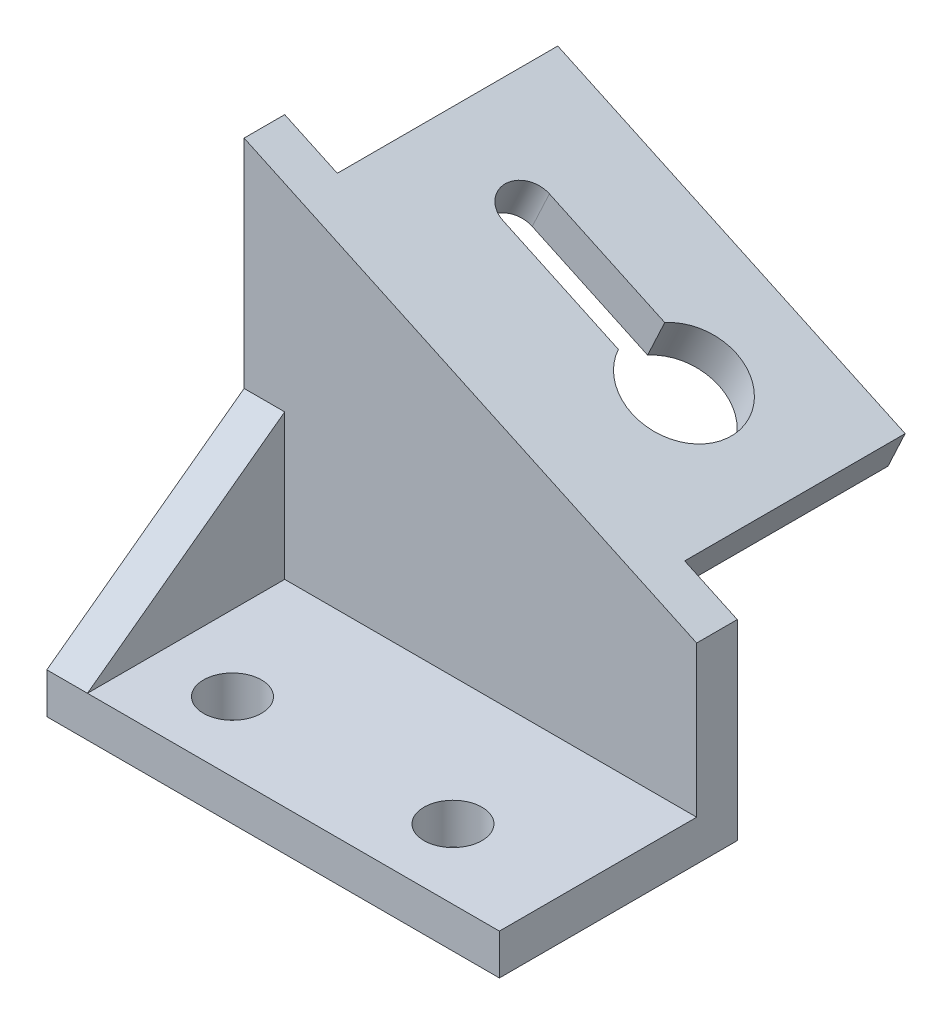
from build123d import *

# Parameters (mm, degrees)
BOSS_EXTRUDE1_DEPTH = 79
SKETCH2_W           = 34
SKETCH2_H           = 36.371997336
CUT_EXTRUDE1_DEPTH  = 71
SKETCH2_4_W         = 34
SKETCH2_4_H         = 36.371997336
CUT_EXTRUDE2_DEPTH  = 79
SKETCH3_W           = 10
SKETCH3_H           = 38
SKETCH3_W_2         = 41.460526603
CUT_EXTRUDE3_DEPTH  = 63.872381388
SKETCH4_W           = 38
SKETCH4_H           = 64.41245134
CUT_EXTRUDE4_DEPTH  = 77.063477679
SKETCH5_R           = 5
CUT_EXTRUDE5_DEPTH  = 8


with BuildPart() as part:
    # Sketch1 → Boss-Extrude1 (new body)
    with BuildSketch(Plane.XY):
        Polygon((78, 33), (0, 69.371997336), (0, 0), (78, 0), align=None)
    extrude(amount=-BOSS_EXTRUDE1_DEPTH)

    # Sketch2 → Cut-Extrude1 (cut)
    with BuildSketch(Plane(origin=(78, 0, 0), x_dir=(0, 0, -1), z_dir=(1, 0, 0))):
        Polygon((0, 33), (0, 7), (34, 32), (34, 33), align=None)
        with Locations((17, 51.185998668)):
            Rectangle(SKETCH2_W, SKETCH2_H)
        Polygon((34, 32), (0, 7), (34, 7), align=None)
    extrude(amount=-CUT_EXTRUDE1_DEPTH, mode=Mode.SUBTRACT)

    # Sketch2_4 → Cut-Extrude2 (cut, through all)
    with BuildSketch(Plane(origin=(78, 0, 0), x_dir=(0, 0, -1), z_dir=(1, 0, 0))):
        with Locations((17, 51.185998668)):
            Rectangle(SKETCH2_4_W, SKETCH2_4_H)
        Polygon((0, 33), (0, 7), (34, 32), (34, 33), align=None)
    extrude(amount=-CUT_EXTRUDE2_DEPTH, mode=Mode.SUBTRACT)

    # Sketch3 → Cut-Extrude3 (cut, through all)
    with BuildSketch(Plane(origin=(26.571016534, 56.981728841, 0), x_dir=(0.906307787, -0.422618262, 0), z_dir=(0.422618262, 0.906307787, 0))):
        with Locations((-24.317872928, 60)):
            Rectangle(SKETCH3_W, SKETCH3_H)
        with Locations((77.475868053, 60)):
            Rectangle(SKETCH3_W_2, SKETCH3_H)
        with Locations((51.745604751, 60)):
            Rectangle(SKETCH3_W, SKETCH3_H)
        with BuildLine():
            ThreePointArc((-3.254395249, 63), (-7.254395249, 59), (-3.254395249, 55))
            Line((-3.254395249, 55), (18.683347003, 55))
            ThreePointArc((18.683347003, 55), (35.745604751, 59), (18.683347003, 63))
            Line((18.683347003, 63), (-3.254395249, 63))
        make_face()
    extrude(amount=-CUT_EXTRUDE3_DEPTH, mode=Mode.SUBTRACT)

    # Sketch4 → Cut-Extrude4 (cut, through all)
    with BuildSketch(Plane(origin=(42.365905596, -19.755546224, 0), x_dir=(0, 0, -1), z_dir=(0.906307787, -0.422618262, 0))):
        with Locations((60, 23.666155718)):
            Rectangle(SKETCH4_W, SKETCH4_H)
    extrude(amount=-CUT_EXTRUDE4_DEPTH, mode=Mode.SUBTRACT)

    # Sketch5 → Cut-Extrude5 (cut, through all)
    with BuildSketch(Plane(origin=(0, 7, 0), x_dir=(1, 0, 0), z_dir=(0, 1, 0))):
        with Locations((20, 12)):
            Circle(SKETCH5_R)
        with Locations((58, 12)):
            Circle(SKETCH5_R)
    extrude(amount=-CUT_EXTRUDE5_DEPTH, mode=Mode.SUBTRACT)


solid = part.part
